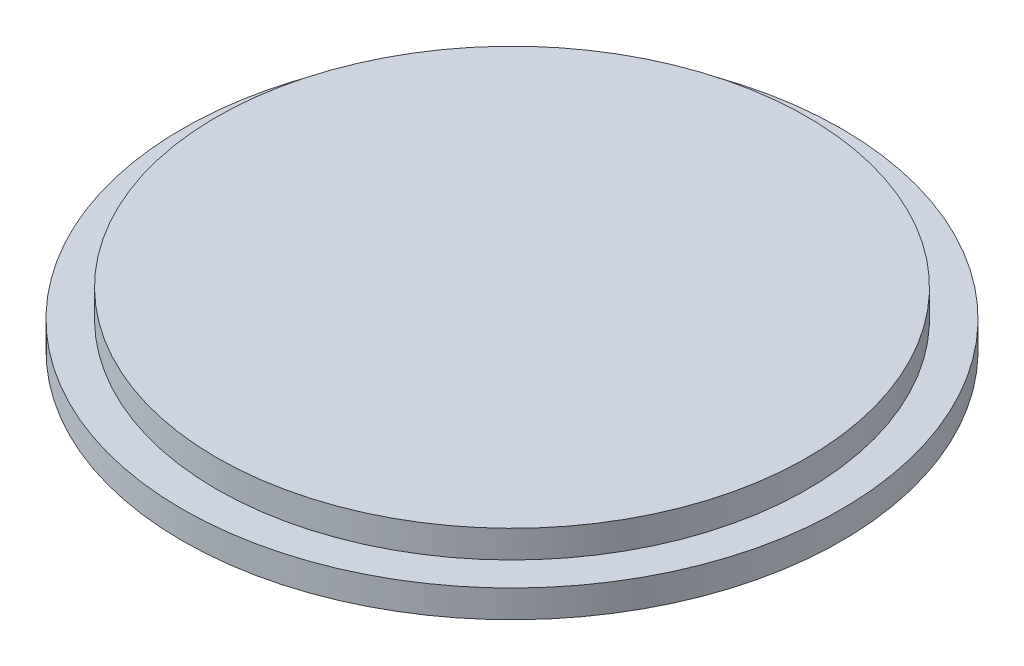
from build123d import *

# Parameters (mm, degrees)
CROQUIS1_R              = 12
CROQUIS1_R_2            = 10.75
SALIENTE_EXTRUIR1_DEPTH = 1
CROQUIS1_2_R            = 10.75
SALIENTE_EXTRUIR2_DEPTH = 2


with BuildPart() as part:
    # Croquis1 → Saliente-Extruir1 (new body)
    with BuildSketch(Plane(origin=(0, 0, 0), x_dir=(1, 0, 0), z_dir=(0, 1, 0))):
        Circle(CROQUIS1_R)
        Circle(CROQUIS1_R_2, mode=Mode.SUBTRACT)
    extrude(amount=SALIENTE_EXTRUIR1_DEPTH)

    # Croquis1_2 → Saliente-Extruir2 (add)
    with BuildSketch(Plane(origin=(0, 0, 0), x_dir=(1, 0, 0), z_dir=(0, 1, 0))):
        Circle(CROQUIS1_2_R)
    extrude(amount=SALIENTE_EXTRUIR2_DEPTH)


solid = part.part
